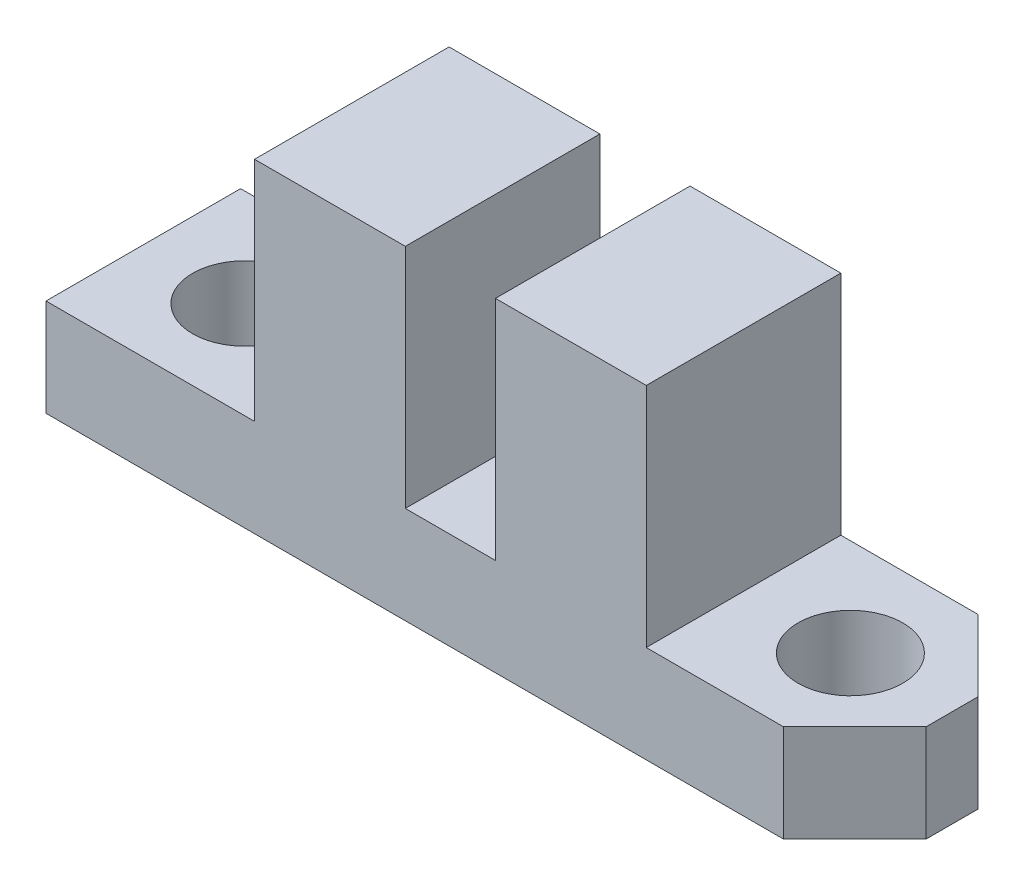
from build123d import *

# Parameters (mm, degrees)
SKETCH1_W           = 24.94
SKETCH1_H           = 6
BOSS_EXTRUDE1_DEPTH = 3
SKETCH2_W           = 4.65
SKETCH2_H           = 6
BOSS_EXTRUDE2_DEPTH = 7
SKETCH3_R           = 1.615
CUT_EXTRUDE1_DEPTH  = 4
CHAMFER2_SIZE       = 2.2


with BuildPart() as part:
    # Sketch1 → Boss-Extrude1 (new body)
    with BuildSketch(Plane(origin=(0, 0, 0), x_dir=(1, 0, 0), z_dir=(0, 1, 0))):
        Rectangle(SKETCH1_W, SKETCH1_H)
    extrude(amount=BOSS_EXTRUDE1_DEPTH)

    # Sketch2 → Boss-Extrude2 (add)
    with BuildSketch(Plane(origin=(0, 3, 0), x_dir=(1, 0, 0), z_dir=(0, 1, 0))):
        with Locations((-3.715, 0)):
            Rectangle(SKETCH2_W, SKETCH2_H)
    boss_extrude2 = extrude(amount=BOSS_EXTRUDE2_DEPTH)

    # Sketch3 → Cut-Extrude1 (cut, through all)
    with BuildSketch(Plane(origin=(0, 3, 0), x_dir=(1, 0, 0), z_dir=(0, 1, 0))):
        with Locations((-9.335, 0)):
            Circle(SKETCH3_R)
    cut_extrude1 = extrude(amount=-CUT_EXTRUDE1_DEPTH, mode=Mode.SUBTRACT)

    # Mirror1: Boss-Extrude2, Cut-Extrude1 across plane
    add(boss_extrude2.mirror(Plane(origin=(0, 0, 0), x_dir=(0, 0, 1), z_dir=(1, 0, 0))))
    add(cut_extrude1.mirror(Plane(origin=(0, 0, 0), x_dir=(0, 0, 1), z_dir=(1, 0, 0))), mode=Mode.SUBTRACT)

    # Chamfer2
    chamfer2_edges = [part.edges().sort_by_distance(p)[0] for p in [
        (12.47, 1.5, 3),
        (12.47, 1.5, -3),
    ]]
    chamfer(chamfer2_edges, length=CHAMFER2_SIZE)


solid = part.part
